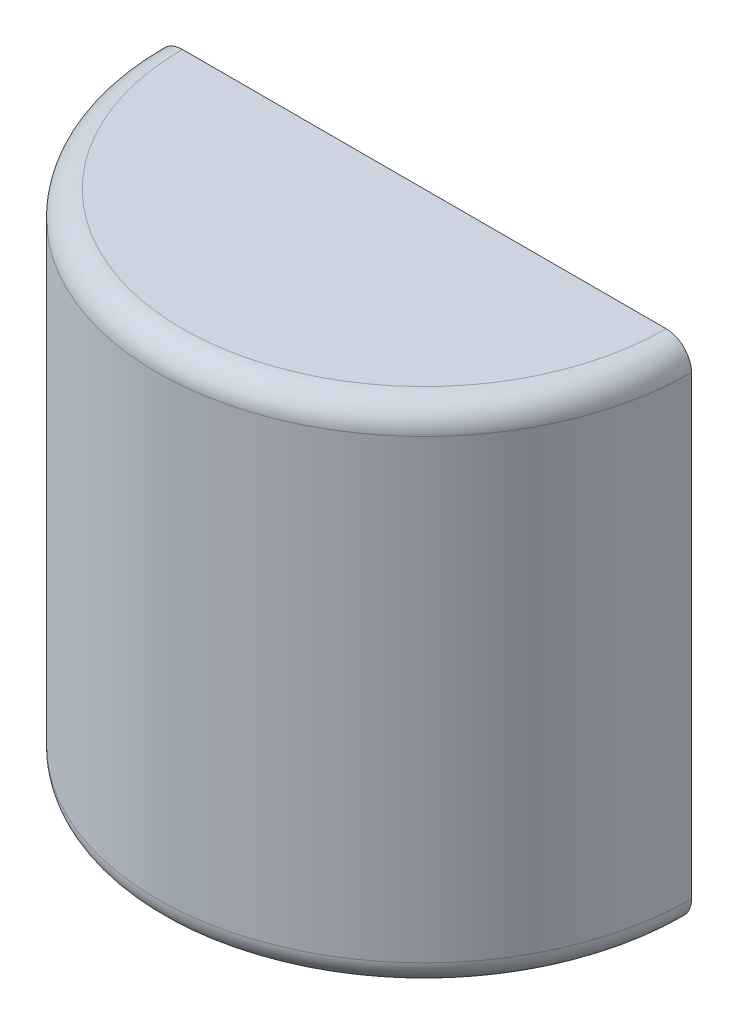
from build123d import *

# Parameters (mm, degrees)
SKETCH1_W      = 133.985
SKETCH1_H      = 254
REVOLVE1_ANGLE = 180
FILLET1_R      = 12.7


with BuildPart() as part:
    # Sketch1 → Revolve1 (revolve)
    with BuildSketch(Plane.XY):
        with Locations((-66.9925, 127)):
            Rectangle(SKETCH1_W, SKETCH1_H)
    revolve(axis=Axis((0, 0, 0), (0, 1, 0)), revolution_arc=REVOLVE1_ANGLE)

    # Fillet1
    fillet1_edges = [part.edges().sort_by_distance(p)[0] for p in [
        (0, 0, 133.985),
        (0, 254, 133.985),
    ]]
    fillet(fillet1_edges, radius=FILLET1_R)


solid = part.part
